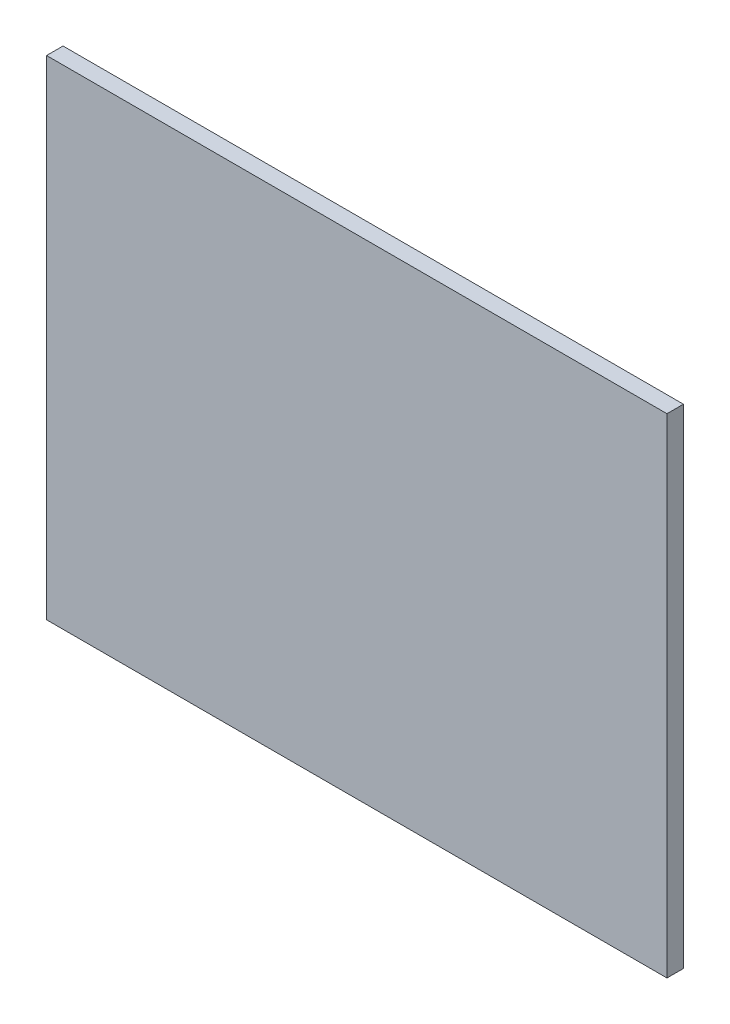
from build123d import *

# Parameters (mm, degrees)
SKIZZE1_W                       = 603
SKIZZE1_H                       = 475
AUFSATZ_LINEAR_AUSTRAGEN1_DEPTH = 16


with BuildPart() as part:
    # Skizze1 → Aufsatz-Linear austragen1 (new body)
    with BuildSketch(Plane.XY):
        Rectangle(SKIZZE1_W, SKIZZE1_H)
    extrude(amount=AUFSATZ_LINEAR_AUSTRAGEN1_DEPTH)


solid = part.part
